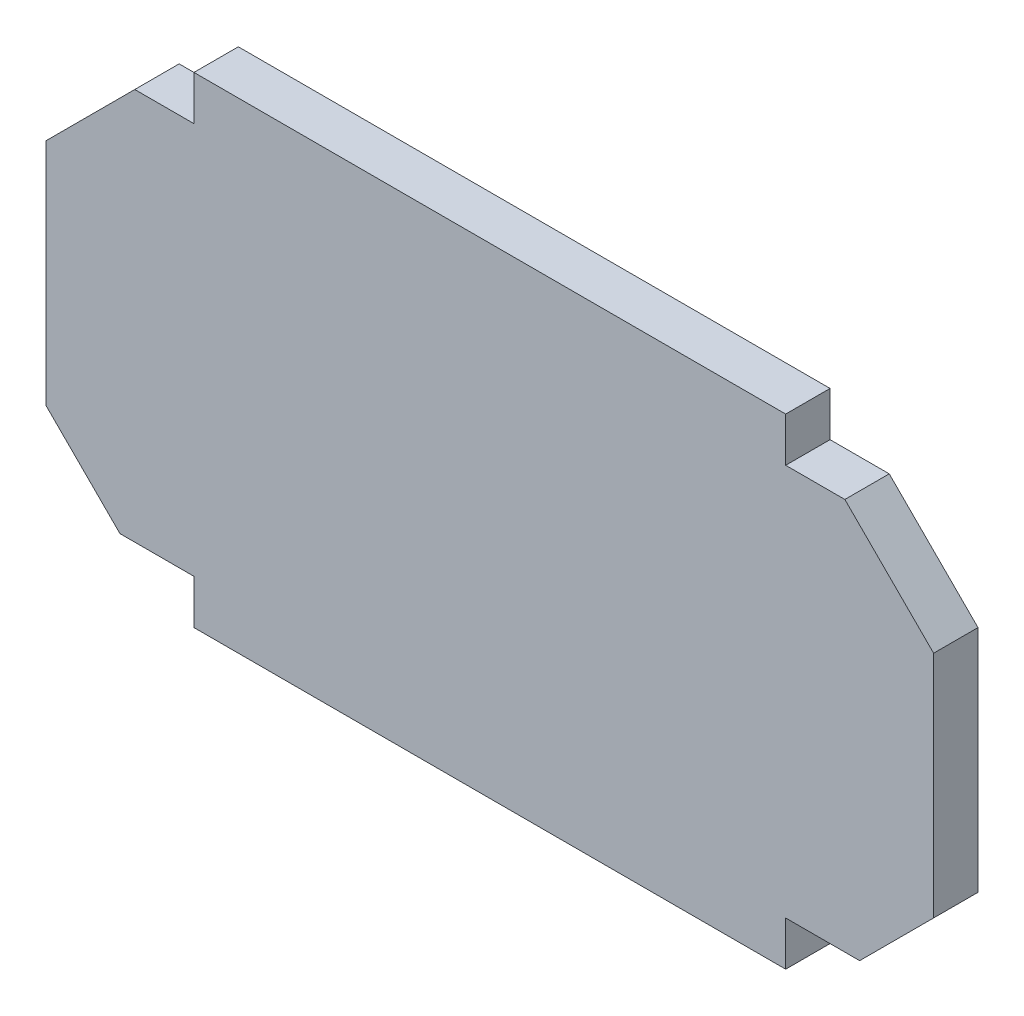
from build123d import *

# Parameters (mm, degrees)
BOSS_EXTRUDE2_DEPTH = 3


with BuildPart() as part:
    # Sketch1 → Boss-Extrude2 (new body)
    with BuildSketch(Plane.XY):
        Polygon((20, 34.5), (-20, 34.5), (-20, 31.5), (-24, 31.5), (-30, 25.5), (-30, 10), (-25, 5), (-20, 5), (-20, 2), (20, 2), (20, 5), (25, 5), (30, 10), (30, 25.5), (24, 31.5), (20, 31.5), align=None)
    extrude(amount=BOSS_EXTRUDE2_DEPTH)


solid = part.part
